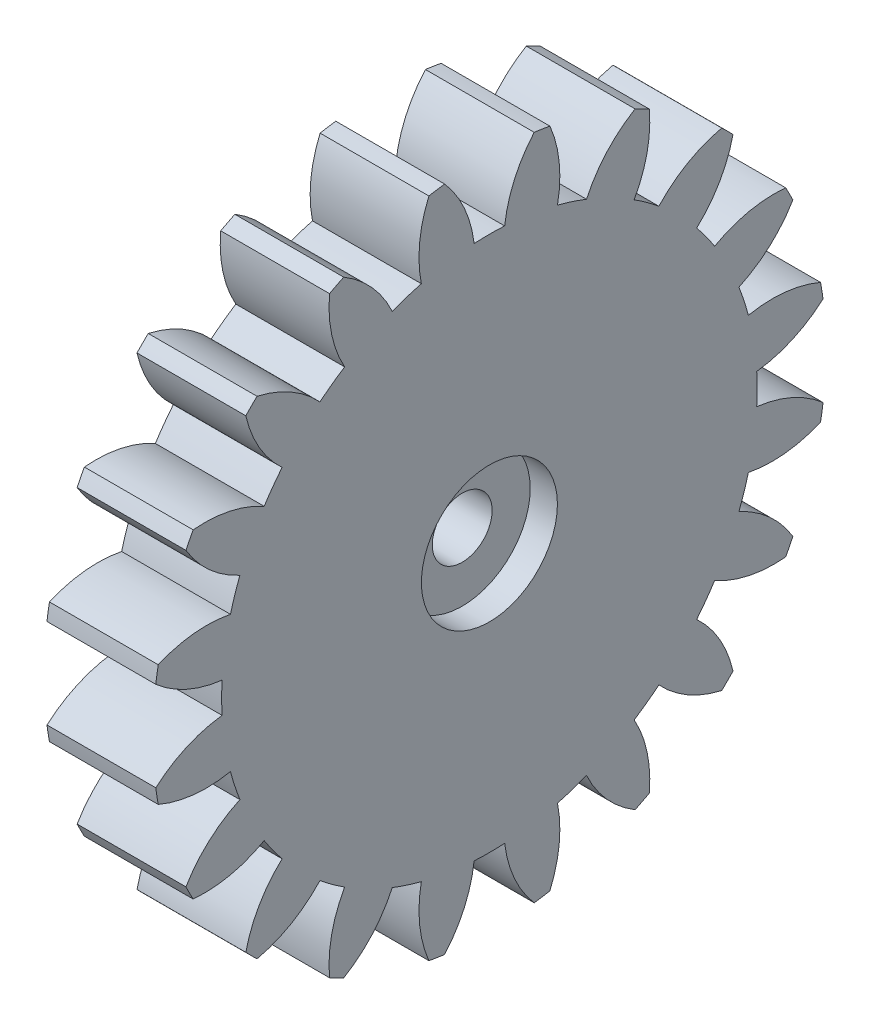
from build123d import *

# Parameters (mm, degrees)
BASPROSKE_W          = 4
BASPROSKE_H          = 12.375
TOOTHCUT_DEPTH       = 18.952193459
TEETHCUTS_COUNT      = 20
M2_CLEARANCE_HOLE1_D = 2.2
SKETCH3_R            = 2.5
CUT_EXTRUDE1_DEPTH   = 1


with BuildPart() as part:
    # BasProSke → Base-Revolve (revolve)
    with BuildSketch(Plane(origin=(0, 0, 0), x_dir=(1, 0, 0), z_dir=(0, 1, 0)), mode=Mode.PRIVATE) as base_revolve_sk:
        with Locations((2, 6.1875)):
            Rectangle(BASPROSKE_W, BASPROSKE_H)
    revolve(base_revolve_sk.sketch.rotate(Axis((-10, 0, 0), (1, 0, 0)), 180), axis=Axis((-10, 0, 0), (1, 0, 0)))

    # TooCutSke → ToothCut (cut, through all)
    with BuildSketch(Plane(origin=(0, 0, 0), x_dir=(0, 0, -1), z_dir=(1, 0, 0))):
        with BuildLine():
            ThreePointArc((0.561279811, 9.826733564), (0, 9.84275), (-0.561279811, 9.826733564))
            ThreePointArc((-0.561279811, 9.826733564), (-0.925277854, 11.14210546), (-1.666860651, 12.287859689))
            ThreePointArc((-1.666860651, 12.287859689), (0, 12.4004), (1.666860651, 12.287859689))
            ThreePointArc((1.666860651, 12.287859689), (0.925277854, 11.14210546), (0.561279811, 9.826733564))
        make_face()
    toothcut = extrude(amount=TOOTHCUT_DEPTH, mode=Mode.SUBTRACT)

    # TeethCuts: ToothCut ×20 about axis
    teethcuts_axis = Axis((0, 0, 0), (1, 0, 0))
    for i in range(1, TEETHCUTS_COUNT):
        add(toothcut.rotate(teethcuts_axis, i * 360 / TEETHCUTS_COUNT), mode=Mode.SUBTRACT)

    # M2 Clearance Hole1 (through all)
    with Locations(Plane(origin=(4, 0, 0), x_dir=(0, 0, -1), z_dir=(1, 0, 0))):
        with Locations((0, 0)):
            Hole(M2_CLEARANCE_HOLE1_D / 2)

    # Sketch3 → Cut-Extrude1 (cut)
    with BuildSketch(Plane(origin=(4, 0, 0), x_dir=(0, 0, -1), z_dir=(1, 0, 0))):
        Circle(SKETCH3_R)
    extrude(amount=-CUT_EXTRUDE1_DEPTH, mode=Mode.SUBTRACT)


solid = part.part
